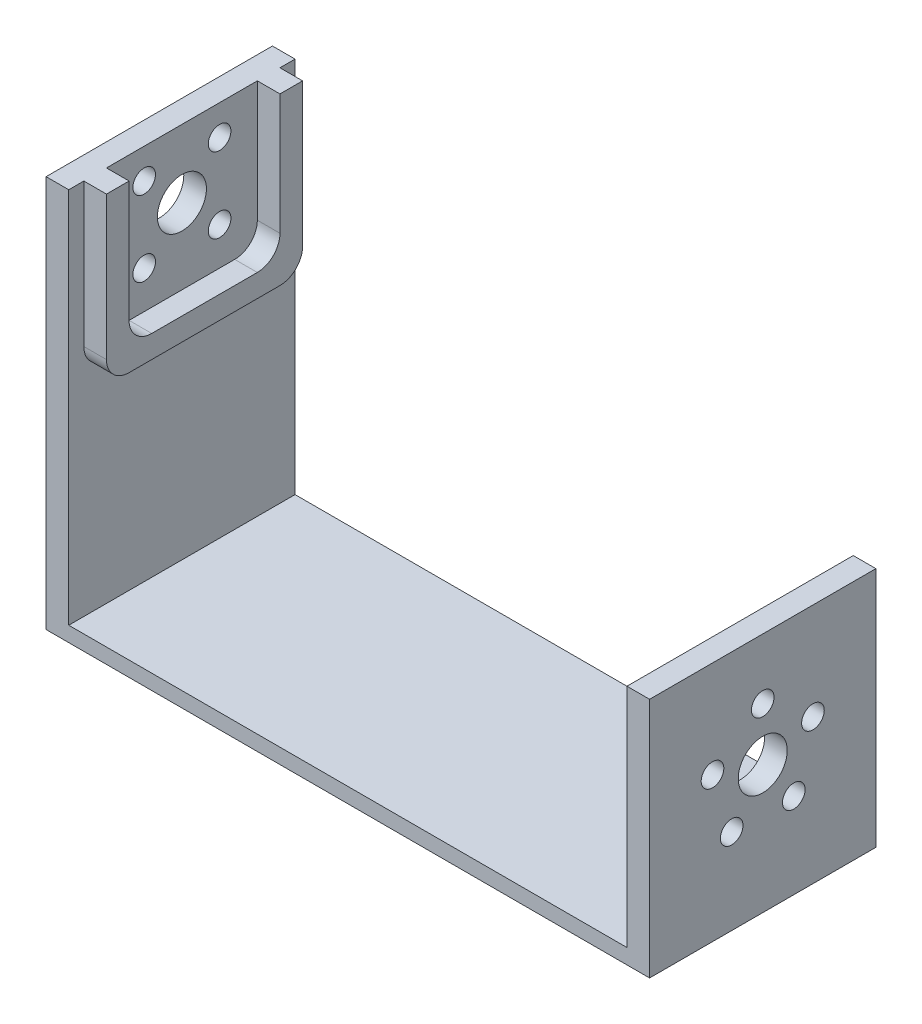
from build123d import *

# Parameters (mm, degrees)
SKETCH1_W            = 80
SKETCH1_H            = 30
CHASSIS_DEPTH        = 2
SKETCH2_W            = 3
SKETCH2_H            = 30
TALLVALVEWALL_DEPTH  = 50
SKETCH3_W            = 3
SKETCH3_H            = 30
SHORTVALVEWALL_DEPTH = 30
SKETCH4_R            = 1.5
SKETCH4_R_2          = 3.25
TALLVALVECUT_DEPTH   = 4
SHORTVALVECUT_REACH  = 82
SKETCH6_R            = 3.25
SKETCH6_R_2          = 1.5
TALLVALVELIP_DEPTH   = 3
LIPROUNDING_R        = 3


with BuildPart() as part:
    # Sketch1 → Chassis (new body)
    with BuildSketch(Plane(origin=(0, 0, 0), x_dir=(1, 0, 0), z_dir=(0, 1, 0))):
        Rectangle(SKETCH1_W, SKETCH1_H)
    extrude(amount=CHASSIS_DEPTH)

    # Sketch2 → TallValveWall (add)
    with BuildSketch(Plane(origin=(0, 2, 0), x_dir=(1, 0, 0), z_dir=(0, 1, 0))):
        with Locations((-38.5, 0)):
            Rectangle(SKETCH2_W, SKETCH2_H)
    extrude(amount=TALLVALVEWALL_DEPTH)

    # Sketch3 → ShortValveWall (add)
    with BuildSketch(Plane(origin=(0, 2, 0), x_dir=(1, 0, 0), z_dir=(0, 1, 0))):
        with Locations((38.5, 0)):
            Rectangle(SKETCH3_W, SKETCH3_H)
    extrude(amount=SHORTVALVEWALL_DEPTH)

    # Sketch4 → TallValveCut (cut, through all)
    with BuildSketch(Plane(origin=(-37, 0, 0), x_dir=(0, 0, -1), z_dir=(1, 0, 0))):
        with Locations((-5, 48)):
            Circle(SKETCH4_R)
        with Locations((5, 48)):
            Circle(SKETCH4_R)
        with Locations((5, 38)):
            Circle(SKETCH4_R)
        with Locations((-5, 38)):
            Circle(SKETCH4_R)
        with Locations((0, 43)):
            Circle(SKETCH4_R_2)
    extrude(amount=-TALLVALVECUT_DEPTH, mode=Mode.SUBTRACT)

    # Sketch6 → ShortValveCut (cut, up to next)
    with BuildSketch(Plane(origin=(40, 0, 0), x_dir=(0, 0, -1), z_dir=(1, 0, 0)), mode=Mode.PRIVATE) as shortvalvecut_sk1:
        with Locations((0, 17)):
            Circle(SKETCH6_R)
    shortvalvecut_tool1 = extrude(shortvalvecut_sk1.sketch, amount=-SHORTVALVECUT_REACH, mode=Mode.PRIVATE) & part.part
    add(shortvalvecut_tool1.solids().sort_by_distance((40, 17, 0))[0], mode=Mode.SUBTRACT)
    # Sketch6 → ShortValveCut (cut, up to next)
    with BuildSketch(Plane(origin=(40, 0, 0), x_dir=(0, 0, -1), z_dir=(1, 0, 0)), mode=Mode.PRIVATE) as shortvalvecut_sk2:
        with Locations((0, 24)):
            Circle(SKETCH6_R_2)
    shortvalvecut_tool2 = extrude(shortvalvecut_sk2.sketch, amount=-SHORTVALVECUT_REACH, mode=Mode.PRIVATE) & part.part
    add(shortvalvecut_tool2.solids().sort_by_distance((40, 24, 0))[0], mode=Mode.SUBTRACT)
    # Sketch6 → ShortValveCut (cut, up to next)
    with BuildSketch(Plane(origin=(40, 0, 0), x_dir=(0, 0, -1), z_dir=(1, 0, 0)), mode=Mode.PRIVATE) as shortvalvecut_sk3:
        with Locations((6.657395614, 19.163118961)):
            Circle(SKETCH6_R_2)
    shortvalvecut_tool3 = extrude(shortvalvecut_sk3.sketch, amount=-SHORTVALVECUT_REACH, mode=Mode.PRIVATE) & part.part
    add(shortvalvecut_tool3.solids().sort_by_distance((40, 19.163119, -6.657396))[0], mode=Mode.SUBTRACT)
    # Sketch6 → ShortValveCut (cut, up to next)
    with BuildSketch(Plane(origin=(40, 0, 0), x_dir=(0, 0, -1), z_dir=(1, 0, 0)), mode=Mode.PRIVATE) as shortvalvecut_sk4:
        with Locations((4.114496766, 11.336881039)):
            Circle(SKETCH6_R_2)
    shortvalvecut_tool4 = extrude(shortvalvecut_sk4.sketch, amount=-SHORTVALVECUT_REACH, mode=Mode.PRIVATE) & part.part
    add(shortvalvecut_tool4.solids().sort_by_distance((40, 11.336881, -4.114497))[0], mode=Mode.SUBTRACT)
    # Sketch6 → ShortValveCut (cut, up to next)
    with BuildSketch(Plane(origin=(40, 0, 0), x_dir=(0, 0, -1), z_dir=(1, 0, 0)), mode=Mode.PRIVATE) as shortvalvecut_sk5:
        with Locations((-4.114496766, 11.336881039)):
            Circle(SKETCH6_R_2)
    shortvalvecut_tool5 = extrude(shortvalvecut_sk5.sketch, amount=-SHORTVALVECUT_REACH, mode=Mode.PRIVATE) & part.part
    add(shortvalvecut_tool5.solids().sort_by_distance((40, 11.336881, 4.114497))[0], mode=Mode.SUBTRACT)
    # Sketch6 → ShortValveCut (cut, up to next)
    with BuildSketch(Plane(origin=(40, 0, 0), x_dir=(0, 0, -1), z_dir=(1, 0, 0)), mode=Mode.PRIVATE) as shortvalvecut_sk6:
        with Locations((-6.657395614, 19.163118961)):
            Circle(SKETCH6_R_2)
    shortvalvecut_tool6 = extrude(shortvalvecut_sk6.sketch, amount=-SHORTVALVECUT_REACH, mode=Mode.PRIVATE) & part.part
    add(shortvalvecut_tool6.solids().sort_by_distance((40, 19.163119, 6.657396))[0], mode=Mode.SUBTRACT)

    # Sketch7 → TallValveLip (add)
    with BuildSketch(Plane(origin=(-37, 0, 0), x_dir=(0, 0, -1), z_dir=(1, 0, 0))):
        Polygon((-13, 52), (-10, 52), (-10, 33), (10, 33), (10, 52), (13, 52), (13, 30), (-13, 30), align=None)
    extrude(amount=TALLVALVELIP_DEPTH)

    # LipRounding
    liprounding_edges = [part.edges().sort_by_distance(p)[0] for p in [
        (-35.5, 30, 13),
        (-35.5, 30, -13),
        (-35.5, 33, -10),
        (-35.5, 33, 10),
    ]]
    fillet(liprounding_edges, radius=LIPROUNDING_R)


solid = part.part
